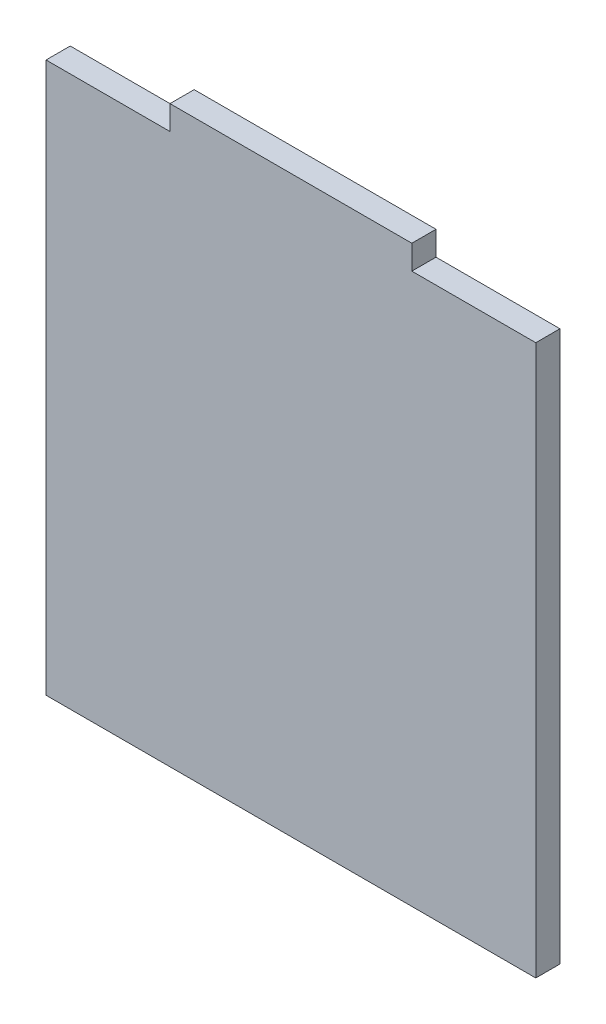
from build123d import *

# Parameters (mm, degrees)
SKETCH2_W           = 128.5875
SKETCH2_H           = 144.4625
BOSS_EXTRUDE1_DEPTH = 6.35
SKETCH3_W           = 63.5
SKETCH3_H           = 6.35
BOSS_EXTRUDE2_DEPTH = 6.35


with BuildPart() as part:
    # Sketch2 → Boss-Extrude1 (new body)
    with BuildSketch(Plane.XY):
        Rectangle(SKETCH2_W, SKETCH2_H)
    extrude(amount=BOSS_EXTRUDE1_DEPTH)

    # Sketch3 → Boss-Extrude2 (add)
    with BuildSketch(Plane.XY.offset(6.35)):
        with Locations((0, 75.40625)):
            Rectangle(SKETCH3_W, SKETCH3_H)
    extrude(amount=-BOSS_EXTRUDE2_DEPTH)


solid = part.part
